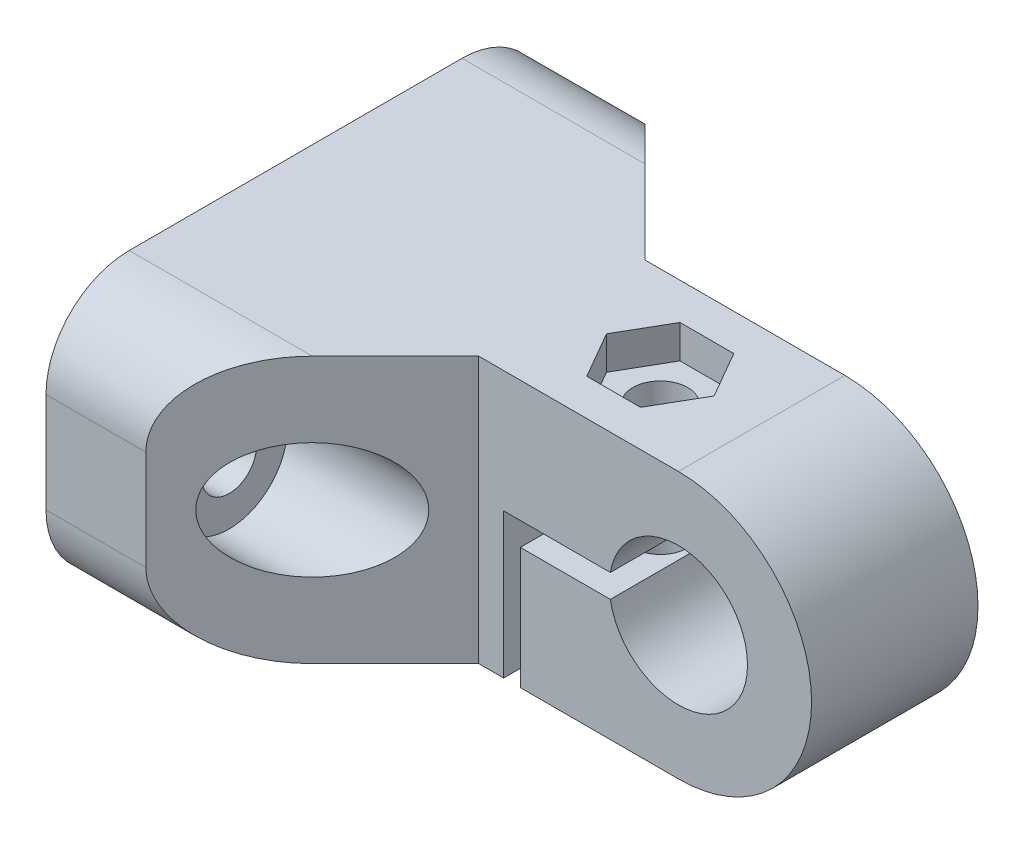
from build123d import *

# Parameters (mm, degrees)
RESSALTO_EXTRUS_O1_DEPTH   = 30
CORTE_EXTRUS_O6_DEPTH      = 17
ESBO_O6_R                  = 1.65
CORTE_EXTRUS_O4_DEPTH      = 9.7
CORTE_EXTRUS_O4_DEPTH_BACK = 8.3
CORTE_EXTRUS_O5_DEPTH      = 2
ESBO_O9_R                  = 1.65
CORTE_EXTRUS_O7_DEPTH      = 37
FILETE1_R                  = 5
ESBO_O10_R                 = 3.5
CORTE_EXTRUS_O8_DEPTH      = 22


with BuildPart() as part:
    # Esboço2 → Ressalto-extrusão1 (new body)
    with BuildSketch(Plane.XY):
        with BuildLine():
            Line((0, 8), (-28, 8))
            Line((-28, 8), (-28, -8))
            Line((-28, -8), (-10.5, -8))
            Line((-10.5, -8), (-10.5, 0.7))
            Line((-10.5, 0.7), (-4.090537862, 0.7))
            ThreePointArc((-4.090537862, 0.7), (4.15, 0), (-4.090537862, -0.7))
            Line((-4.090537862, -0.7), (-9.5, -0.7))
            Line((-9.5, -0.7), (-9.5, -8))
            Line((-9.5, -8), (0, -8))
            ThreePointArc((0, -8), (8, 0), (0, 8))
        make_face()
    extrude(amount=RESSALTO_EXTRUS_O1_DEPTH)

    # Esboço8 → Corte-extrusão6 (cut, through all)
    with BuildSketch(Plane(origin=(0, 8, 0), x_dir=(1, 0, 0), z_dir=(0, 1, 0))):
        Polygon((-22, -30), (-12, -20), (8, -20), (8, -30), align=None)
        Polygon((8, 0), (-22, 0), (-12, -10), (8, -10), align=None)
    extrude(amount=-CORTE_EXTRUS_O6_DEPTH, mode=Mode.SUBTRACT)

    # Esboço6 → Corte-extrusão4 (cut, two sides)
    with BuildSketch(Plane.XZ.offset(-0.7)) as corte_extrus_o4_sk:
        with Locations((-6.090537862, 15)):
            Circle(ESBO_O6_R)
    extrude(amount=CORTE_EXTRUS_O4_DEPTH, mode=Mode.SUBTRACT)
    extrude(corte_extrus_o4_sk.sketch, amount=-CORTE_EXTRUS_O4_DEPTH_BACK, mode=Mode.SUBTRACT)

    # Esboço7 → Corte-extrusão5 (cut)
    with BuildSketch(Plane(origin=(0, 8, 0), x_dir=(1, 0, 0), z_dir=(0, 1, 0))):
        Polygon((-2.857376354, -15), (-4.473957108, -12.2), (-7.707118616, -12.2), (-9.323699369, -15), (-7.707118616, -17.8), (-4.473957108, -17.8), align=None)
    extrude(amount=-CORTE_EXTRUS_O5_DEPTH, mode=Mode.SUBTRACT)

    # Esboço9 → Corte-extrusão7 (cut, through all)
    with BuildSketch(Plane(origin=(-28, 0, 19.455844123), x_dir=(0, 0, -1), z_dir=(1, 0, 0))):
        with Locations((14.455844123, 0)):
            Circle(ESBO_O9_R)
        with Locations((-5.544155877, 0)):
            Circle(ESBO_O9_R)
    extrude(amount=CORTE_EXTRUS_O7_DEPTH, mode=Mode.SUBTRACT)

    # Filete1
    filete1_edges = [part.edges().sort_by_distance(p)[0] for p in [
        (-25, -8, 0),
        (-25, 8, 30),
        (-25, -8, 30),
        (-25, 8, 0),
    ]]
    fillet(filete1_edges, radius=FILETE1_R)

    # Esboço10 → Corte-extrusão8 (cut)
    with BuildSketch(Plane(origin=(0, 0, 0), x_dir=(0, 0, -1), z_dir=(1, 0, 0))):
        with Locations((-25, 0)):
            Circle(ESBO_O10_R)
        with Locations((-5, 0)):
            Circle(ESBO_O10_R)
    extrude(amount=-CORTE_EXTRUS_O8_DEPTH, mode=Mode.SUBTRACT)


solid = part.part
